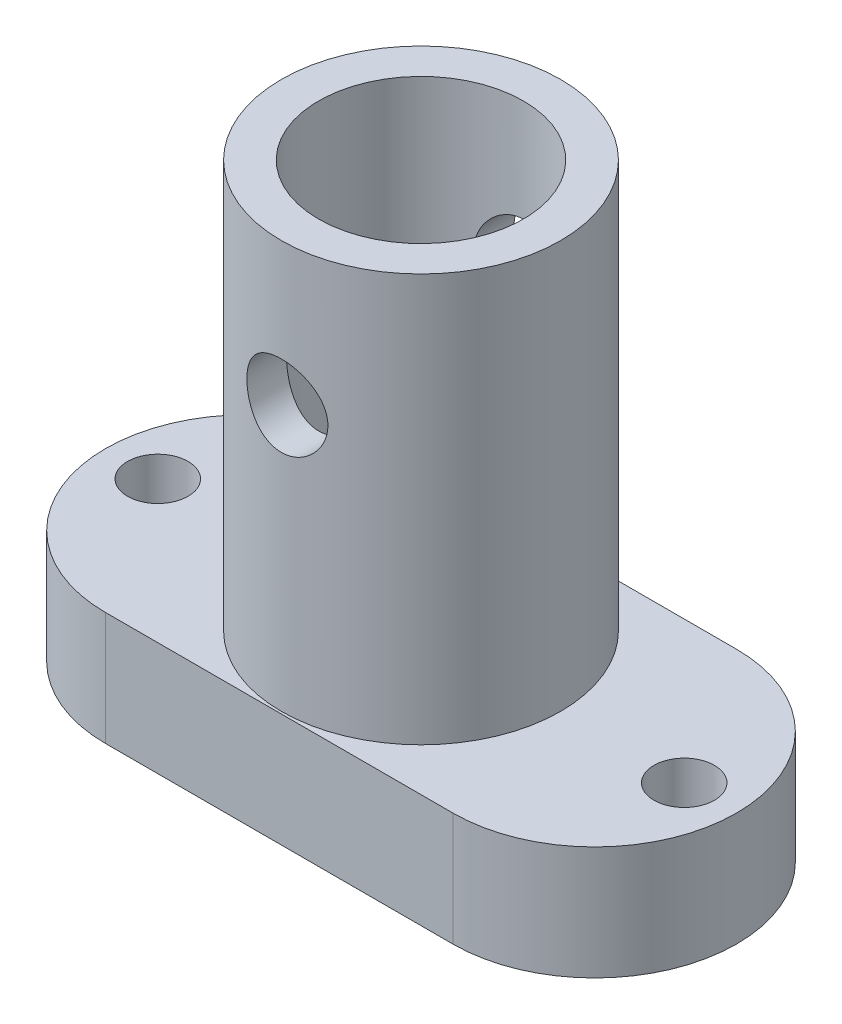
from build123d import *

# Parameters (mm, degrees)
SKETCH1_R               = 1.2192
BOSS_EXTRUDE1_DEPTH     = 4.572
SKETCH1_3_R             = 5.625
SKETCH1_3_R_2           = 4.125
BOSS_EXTRUDE2_DEPTH     = 21
CUT_EXTRUDE1_DEPTH      = 18.923
CUT_EXTRUDE1_DEPTH_BACK = 18.923
SKETCH2_R               = 1.63195


with BuildPart() as part:
    # Sketch1 → Boss-Extrude1 (new body)
    with BuildSketch(Plane(origin=(0, 0, 0), x_dir=(1, 0, 0), z_dir=(0, 1, 0))):
        with BuildLine():
            Line((17.6045, 5.715), (3.6045, 5.715))
            ThreePointArc((3.6045, 5.715), (-2.1105, 0), (3.6045, -5.715))
            Line((3.6045, -5.715), (17.6045, -5.715))
            ThreePointArc((17.6045, -5.715), (23.3195, 0), (17.6045, 5.715))
        make_face()
        Circle(SKETCH1_R, mode=Mode.SUBTRACT)
        with Locations((21.209, 0)):
            Circle(SKETCH1_R, mode=Mode.SUBTRACT)
    extrude(amount=BOSS_EXTRUDE1_DEPTH)

    # Sketch1_3 → Boss-Extrude2 (add)
    with BuildSketch(Plane(origin=(0, 0, 0), x_dir=(1, 0, 0), z_dir=(0, 1, 0))):
        with Locations((10.6045, 0)):
            Circle(SKETCH1_3_R)
        with Locations((10.6045, 0)):
            Circle(SKETCH1_3_R_2, mode=Mode.SUBTRACT)
    extrude(amount=BOSS_EXTRUDE2_DEPTH)

    # Sketch2 → Cut-Extrude1 (cut, two sides: drawn at the far end of the back side and taken through both)
    with BuildSketch(Plane.XY.offset(-CUT_EXTRUDE1_DEPTH_BACK)):
        with Locations((10.6045, 15.24)):
            Circle(SKETCH2_R)
    extrude(amount=CUT_EXTRUDE1_DEPTH + CUT_EXTRUDE1_DEPTH_BACK, mode=Mode.SUBTRACT)


solid = part.part
